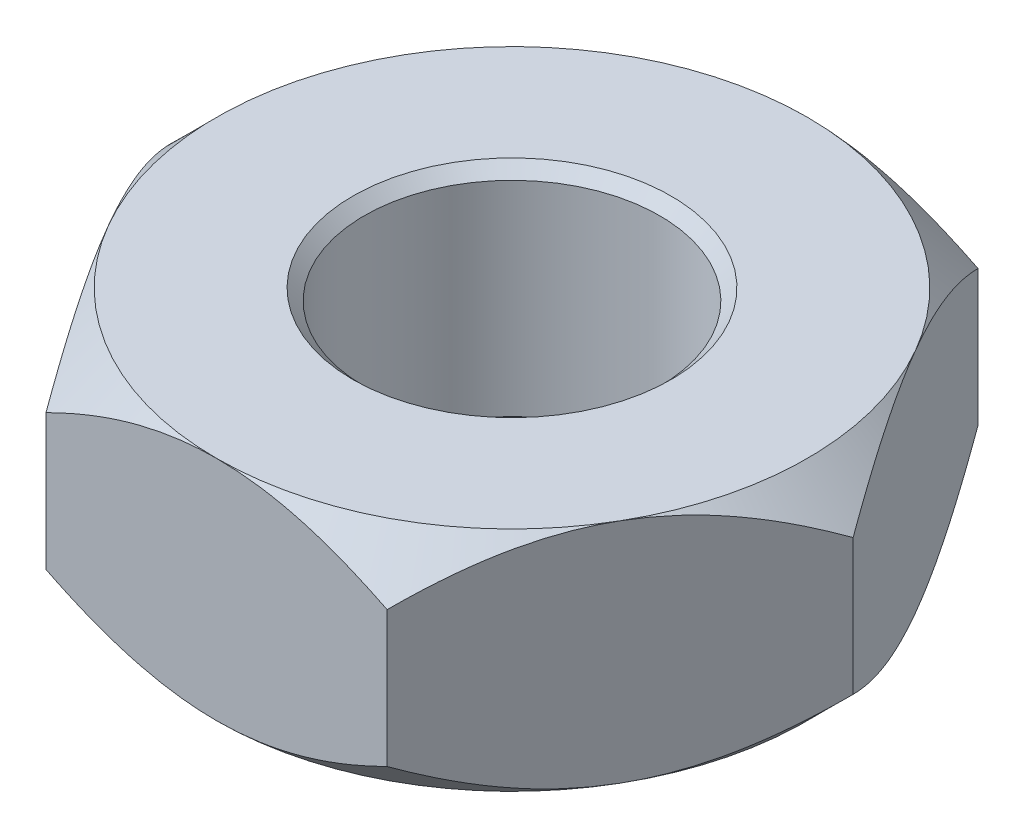
from build123d import *

# Parameters (mm, degrees)
SKETCH1_R           = 3.25
BOSS_EXTRUDE1_DEPTH = 5
CHAMFER2_SIZE       = 0.25


with BuildPart() as part:
    # Sketch1 → Boss-Extrude1 (new body)
    with BuildSketch(Plane(origin=(0, 0, 0), x_dir=(1, 0, 0), z_dir=(0, 1, 0))):
        Polygon((3.75277675, -6.5), (7.505553499, 0), (3.75277675, 6.5), (-3.75277675, 6.5), (-7.505553499, 0), (-3.75277675, -6.5), align=None)
        Circle(SKETCH1_R, mode=Mode.SUBTRACT)
    extrude(amount=BOSS_EXTRUDE1_DEPTH)

    # Sketch2 → Cut-Revolve1 (revolve, cut)
    with BuildSketch(Plane(origin=(0, 0, 0), x_dir=(0, 0, -1), z_dir=(1, 0, 0))):
        Polygon((6.5, 5), (7.55, 6.05), (7.55, 3.95), align=None)
        Polygon((7.55, 1.05), (6.5, 0), (7.55, -1.05), align=None)
    revolve(axis=Axis((0, 5, 0), (0, -1, 0)), mode=Mode.SUBTRACT)

    # Chamfer2
    chamfer2_edges = [part.edges().sort_by_distance(p)[0] for p in [
        (-3.25, 5, 0),
        (-3.25, 0, 0),
    ]]
    chamfer(chamfer2_edges, length=CHAMFER2_SIZE)


solid = part.part
